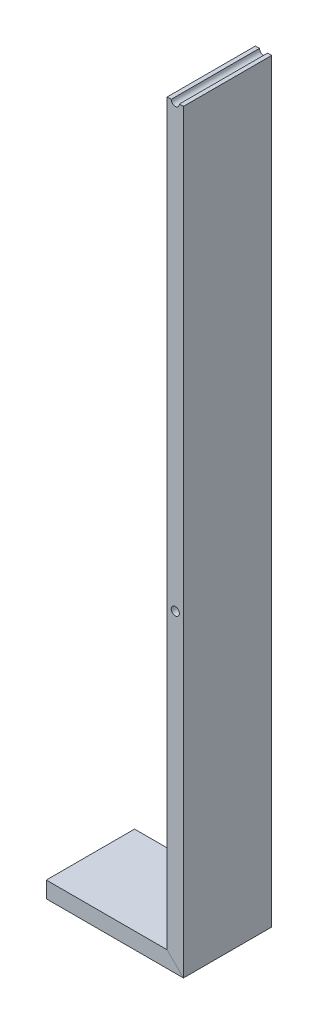
from build123d import *

# Parameters (mm, degrees)
SZKIC2_W                   = 130
SZKIC2_H                   = 24
SZKIC3_R                   = 6
WYTNIJ_WYCI_GNI_CIE1_DEPTH = 131


with BuildPart() as part:
    # Wyciągnięcie po ścieżce1: sweep along a path in Szkic1
    with BuildLine(Plane.XY) as wyci_gni_cie_po_cie_ce1_path:
        Line((0, 0), (190, 0))
        Line((190, 0), (190, 1100))
    # Szkic2 → Wyciągnięcie po ścieżce1 (sweep)
    with BuildSketch(Plane(origin=(0, 0, 0), x_dir=(0, 0, -1), z_dir=(1, 0, 0))):
        Rectangle(SZKIC2_W, SZKIC2_H)
    sweep(path=wyci_gni_cie_po_cie_ce1_path.line, transition=Transition.RIGHT)

    # Szkic3 → Wytnij-wyciągnięcie1 (cut, through all)
    with BuildSketch(Plane.XY.offset(65)):
        with Locations((190, 1100)):
            Circle(SZKIC3_R)
        with Locations((190, 450)):
            Circle(SZKIC3_R)
    extrude(amount=-WYTNIJ_WYCI_GNI_CIE1_DEPTH, mode=Mode.SUBTRACT)


solid = part.part
